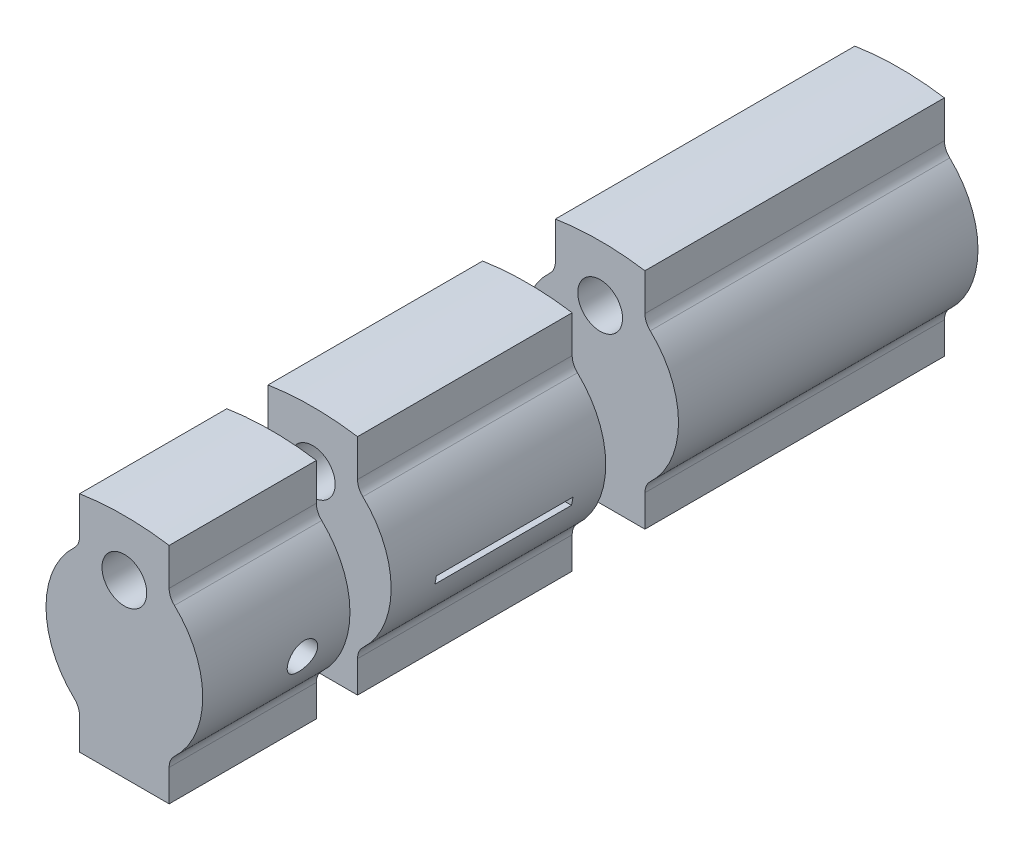
from build123d import *

# Parameters (mm, degrees)
SKETCH1_R               = 12.7
BOSS_EXTRUDE1_DEPTH     = 711.2
FILLET1_R               = 9.525
SKETCH2_W               = 95.25
SKETCH2_H               = 3.175
CUT_EXTRUDE1_DEPTH      = 1400.048
SKETCH3_R               = 13.346875
SKETCH3_R_2             = 6.746875
SKETCH3_W               = 77.49375
SKETCH3_H               = 4.46875
CUT_EXTRUDE2_DEPTH      = 1400.048
CUT_EXTRUDE2_DEPTH_BACK = 1400.048
SKETCH4_R               = 15.5
SKETCH4_R_2             = 8.5
CUT_EXTRUDE3_DEPTH      = 45.4500001
CUT_EXTRUDE3_DEPTH_BACK = 45.4500001
CUT_EXTRUDE4_DEPTH      = 38.1
CUT_EXTRUDE5_DEPTH      = 23.350000036
SKETCH7_R               = 90.857571738
CUT_EXTRUDE6_DEPTH      = 302.514


with BuildPart() as part:
    # Sketch1 → Boss-Extrude1 (new body)
    with BuildSketch(Plane.XY):
        with BuildLine():
            Line((-25.4, -65.0875), (25.4, -65.0875))
            Line((25.4, -65.0875), (25.4, -42.83073728))
            ThreePointArc((25.4, -42.83073728), (44.45, -3.17499999), (25.4, 36.4807373))
            Line((25.4, 36.4807373), (25.4, 61.8807373))
            ThreePointArc((25.4, 61.8807373), (0, 63.846283551), (-25.4, 61.8807373))
            Line((-25.4, 61.8807373), (-25.4, 36.4807373))
            ThreePointArc((-25.4, 36.4807373), (-44.45, -3.17499999), (-25.4, -42.83073728))
            Line((-25.4, -42.83073728), (-25.4, -65.0875))
        make_face()
        with Locations((0, 32.096283551)):
            Circle(SKETCH1_R, mode=Mode.SUBTRACT)
    extrude(amount=BOSS_EXTRUDE1_DEPTH)

    # Fillet1
    fillet1_edges = [part.edges().sort_by_distance(p)[0] for p in [
        (25.4, 36.4807373, 355.6),
        (25.4, -42.83073728, 355.6),
        (-25.4, -42.83073728, 355.6),
        (-25.4, 36.4807373, 355.6),
    ]]
    fillet(fillet1_edges, radius=FILLET1_R)

    # Sketch2 → Cut-Extrude1 (cut)
    with BuildSketch(Plane(origin=(-606.966916913, -895.257535636, -922.36020311), x_dir=(1, 0, 0), z_dir=(0, 1, 0))):
        with Locations((606.425, -1093.81020311)):
            Rectangle(SKETCH2_W, SKETCH2_H)
        with Locations((606.425, -1363.68520311)):
            Rectangle(SKETCH2_W, SKETCH2_H)
    extrude(amount=CUT_EXTRUDE1_DEPTH, mode=Mode.SUBTRACT)

    # Sketch3 → Cut-Extrude2 (cut, two sides)
    with BuildSketch(Plane(origin=(0, 0, 0), x_dir=(0, 0, -1), z_dir=(1, 0, 0))) as cut_extrude2_sk:
        with Locations((-191.770000017, -12.5920627)):
            Circle(SKETCH3_R)
        with Locations((-382.270000017, -12.5920627)):
            Circle(SKETCH3_R_2)
        with Locations((-267.97, -12.5920627)):
            Rectangle(SKETCH3_W, SKETCH3_H)
    extrude(amount=CUT_EXTRUDE2_DEPTH, mode=Mode.SUBTRACT)
    extrude(cut_extrude2_sk.sketch, amount=-CUT_EXTRUDE2_DEPTH_BACK, mode=Mode.SUBTRACT)

    # Sketch4 → Cut-Extrude3 (cut, two sides)
    with BuildSketch(Plane(origin=(0, 0, 0), x_dir=(0, 0, -1), z_dir=(1, 0, 0))) as cut_extrude3_sk:
        with Locations((-191.770000017, -12.5920627)):
            Circle(SKETCH4_R)
        with Locations((-382.270000017, -12.5920627)):
            Circle(SKETCH4_R_2)
    extrude(amount=CUT_EXTRUDE3_DEPTH, mode=Mode.SUBTRACT)
    extrude(cut_extrude3_sk.sketch, amount=-CUT_EXTRUDE3_DEPTH_BACK, mode=Mode.SUBTRACT)

    # Sketch5 → Cut-Extrude4 (cut)
    with BuildSketch(Plane(origin=(0, 0, 173.0375), x_dir=(-1, 0, 0), z_dir=(0, 0, -1))):
        with BuildLine():
            Line((25.4, 40.819090522), (25.4, 61.8807373))
            ThreePointArc((25.4, 61.8807373), (0, 63.846283551), (-25.4, 61.8807373))
            Line((-25.4, 61.8807373), (-25.4, 40.819090522))
            ThreePointArc((-25.4, 40.819090522), (-26.18426054, 37.034239312), (-28.407894737, 33.872655178))
            ThreePointArc((-28.407894737, 33.872655178), (-44.45, -3.17499999), (-28.407894737, -40.222655158))
            ThreePointArc((-28.407894737, -40.222655158), (-26.18426054, -43.384239292), (-25.4, -47.169090502))
            Line((-25.4, -47.169090502), (-25.4, -65.0875))
            Line((-25.4, -65.0875), (25.4, -65.0875))
            Line((25.4, -65.0875), (25.4, -47.169090502))
            ThreePointArc((25.4, -47.169090502), (26.18426054, -43.384239292), (28.407894737, -40.222655158))
            ThreePointArc((28.407894737, -40.222655158), (44.45, -3.17499999), (28.407894737, 33.872655178))
            ThreePointArc((28.407894737, 33.872655178), (26.18426054, 37.034239312), (25.4, 40.819090522))
        make_face()
    extrude(amount=-CUT_EXTRUDE4_DEPTH, mode=Mode.SUBTRACT)

    # Sketch6 → Cut-Extrude5 (cut)
    with BuildSketch(Plane.XY.offset(356.226000018)):
        with BuildLine():
            Line((-25.4, 61.8807373), (-25.4, 40.819090522))
            ThreePointArc((-25.4, 40.819090522), (-26.18426054, 37.034239312), (-28.407894737, 33.872655178))
            ThreePointArc((-28.407894737, 33.872655178), (-44.45, -3.17499999), (-28.407894737, -40.222655158))
            ThreePointArc((-28.407894737, -40.222655158), (-26.18426054, -43.384239292), (-25.4, -47.169090502))
            Line((-25.4, -47.169090502), (-25.4, -65.0875))
            Line((-25.4, -65.0875), (25.4, -65.0875))
            Line((25.4, -65.0875), (25.4, -47.169090502))
            ThreePointArc((25.4, -47.169090502), (26.18426054, -43.384239292), (28.407894737, -40.222655158))
            ThreePointArc((28.407894737, -40.222655158), (44.45, -3.17499999), (28.407894737, 33.872655178))
            ThreePointArc((28.407894737, 33.872655178), (26.18426054, 37.034239312), (25.4, 40.819090522))
            Line((25.4, 40.819090522), (25.4, 61.8807373))
            ThreePointArc((25.4, 61.8807373), (0, 63.846283551), (-25.4, 61.8807373))
        make_face()
    extrude(amount=-CUT_EXTRUDE5_DEPTH, mode=Mode.SUBTRACT)

    # Sketch7 → Cut-Extrude6 (cut)
    with BuildSketch(Plane(origin=(0, 0, 442.9125), x_dir=(-1, 0, 0), z_dir=(0, 0, -1))):
        Circle(SKETCH7_R)
    extrude(amount=-CUT_EXTRUDE6_DEPTH, mode=Mode.SUBTRACT)


solid = part.part
